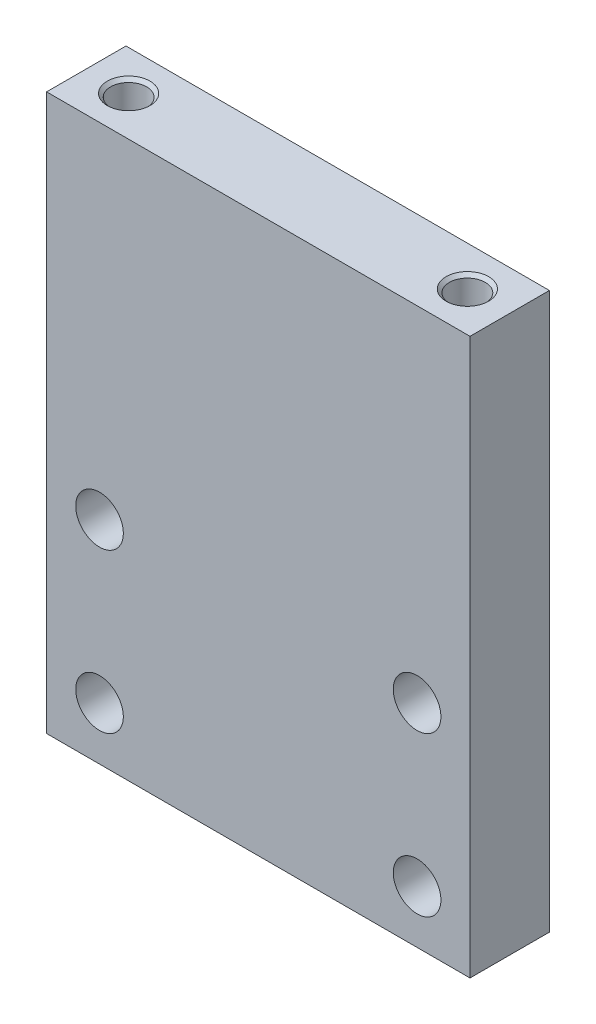
from build123d import *

# Parameters (mm, degrees)
SKETCH_1_W                   = 80
SKETCH_1_H                   = 105
SKETCH_1_R                   = 4.5
EXTRUDE_1_DEPTH              = 15
HOLE_WIZARD_M8_1_D           = 6.8
HOLE_WIZARD_M8_1_DEPTH       = 22.25
HOLE_WIZARD_M8_1_CSINK_D     = 8.05
HOLE_WIZARD_M8_1_CSINK_ANGLE = 90
HOLE_WIZARD_M8_1_TIP         = 2.042926105


with BuildPart() as part:
    # 草图1 → 凸台-拉伸1 (new body)
    with BuildSketch(Plane.XY):
        Rectangle(SKETCH_1_W, SKETCH_1_H)
        with Locations((-30, -12.5)):
            Circle(SKETCH_1_R, mode=Mode.SUBTRACT)
        with Locations((30, -12.5)):
            Circle(SKETCH_1_R, mode=Mode.SUBTRACT)
        with Locations((30, -42.5)):
            Circle(SKETCH_1_R, mode=Mode.SUBTRACT)
        with Locations((-30, -42.5)):
            Circle(SKETCH_1_R, mode=Mode.SUBTRACT)
    extrude(amount=EXTRUDE_1_DEPTH)

    # M8 螺纹孔1
    with Locations(Plane(origin=(-32, 52.5, 7.5), x_dir=(0, 0, 1), z_dir=(0, 1, 0))):
        with Locations((0, 0), (0, 64)):
            CounterSinkHole(HOLE_WIZARD_M8_1_D / 2, HOLE_WIZARD_M8_1_CSINK_D / 2, depth=HOLE_WIZARD_M8_1_DEPTH, counter_sink_angle=HOLE_WIZARD_M8_1_CSINK_ANGLE)
            with Locations((0, 0, -(HOLE_WIZARD_M8_1_DEPTH + HOLE_WIZARD_M8_1_TIP / 2))):  # 118° drill point
                Cone(0, HOLE_WIZARD_M8_1_D / 2, HOLE_WIZARD_M8_1_TIP, mode=Mode.SUBTRACT)


solid = part.part
